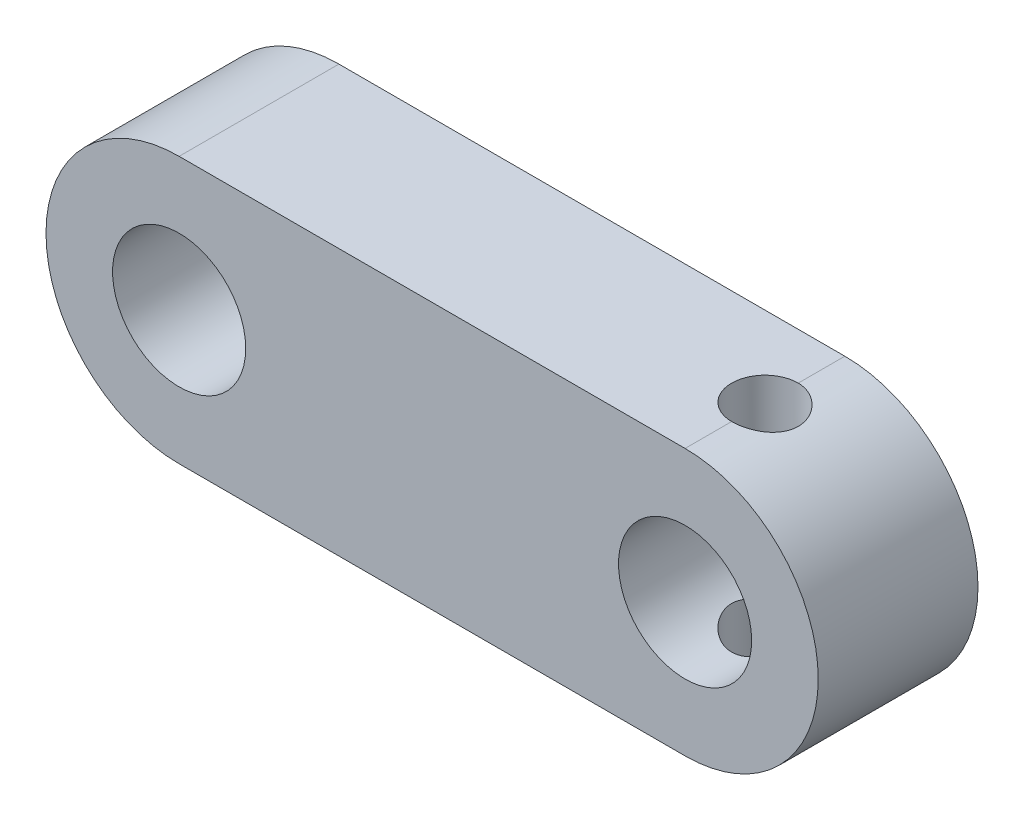
from build123d import *

# Parameters (mm, degrees)
SKETCH1_R           = 2.5
BOSS_EXTRUDE1_DEPTH = 6
SKETCH2_R           = 1.25
CUT_EXTRUDE1_DEPTH  = 10


with BuildPart() as part:
    # Sketch1 → Boss-Extrude1 (new body)
    with BuildSketch(Plane.XY):
        with BuildLine():
            Line((0, 5), (-19, 5))
            ThreePointArc((-19, 5), (-24, 0), (-19, -5))
            Line((-19, -5), (0, -5))
            ThreePointArc((0, -5), (5, 0), (0, 5))
        make_face()
        with Locations((-19, 0)):
            Circle(SKETCH1_R, mode=Mode.SUBTRACT)
        Circle(SKETCH1_R, mode=Mode.SUBTRACT)
    extrude(amount=BOSS_EXTRUDE1_DEPTH)

    # Sketch2 → Cut-Extrude1 (cut)
    with BuildSketch(Plane(origin=(0, 5, 0), x_dir=(1, 0, 0), z_dir=(0, 1, 0))):
        with Locations((0, -3)):
            Circle(SKETCH2_R)
    extrude(amount=-CUT_EXTRUDE1_DEPTH, mode=Mode.SUBTRACT)


solid = part.part
